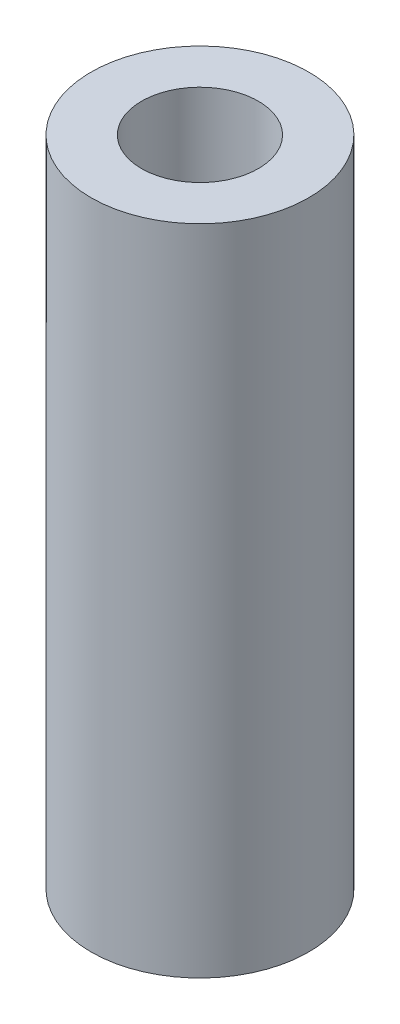
from build123d import *

# Parameters (mm, degrees)
SKETCH1_R           = 1.5875
SKETCH1_R_2         = 0.852069719
BOSS_EXTRUDE1_DEPTH = 9.525


with BuildPart() as part:
    # Sketch1 → Boss-Extrude1 (new body)
    with BuildSketch(Plane(origin=(0, 0, 0), x_dir=(1, 0, 0), z_dir=(0, 1, 0))):
        Circle(SKETCH1_R)
        Circle(SKETCH1_R_2, mode=Mode.SUBTRACT)
    extrude(amount=BOSS_EXTRUDE1_DEPTH)


solid = part.part
